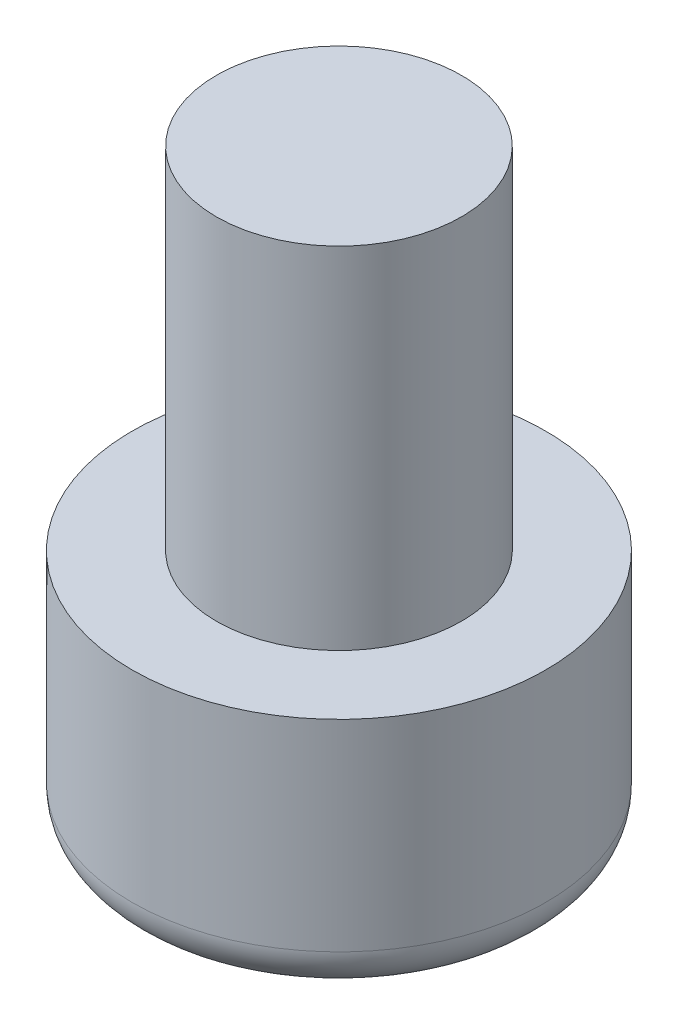
from build123d import *

# Parameters (mm, degrees)
BEARING_PLUG_R            = 4.725
BEARINGPLUG_EXTRUDE_DEPTH = 5.6
SKETCH2_R                 = 2.8
BOSS_EXTRUDE2_DEPTH       = 8
FILLET1_R                 = 1


with BuildPart() as part:
    # Bearing Plug → BearingPlug Extrude (new body)
    with BuildSketch(Plane(origin=(0, 0, 0), x_dir=(1, 0, 0), z_dir=(0, 1, 0))):
        Circle(BEARING_PLUG_R)
    extrude(amount=BEARINGPLUG_EXTRUDE_DEPTH)

    # Sketch2 → Boss-Extrude2 (add)
    with BuildSketch(Plane(origin=(0, 5.6, 0), x_dir=(1, 0, 0), z_dir=(0, 1, 0))):
        Circle(SKETCH2_R)
    extrude(amount=BOSS_EXTRUDE2_DEPTH)

    # Fillet1
    fillet1_edges = [part.edges().sort_by_distance(p)[0] for p in [
        (-4.725, 0, 0),
    ]]
    fillet(fillet1_edges, radius=FILLET1_R)


solid = part.part
